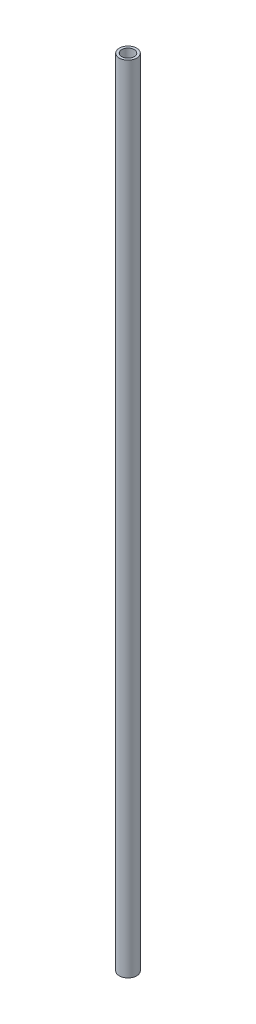
from build123d import *

# Parameters (mm, degrees)
SKETCH1_R           = 13.335
SKETCH1_R_2         = 9.525
BOSS_EXTRUDE1_DEPTH = 1219.2


with BuildPart() as part:
    # Sketch1 → Boss-Extrude1 (new body)
    with BuildSketch(Plane(origin=(0, 0, 0), x_dir=(1, 0, 0), z_dir=(0, 1, 0))):
        Circle(SKETCH1_R)
        Circle(SKETCH1_R_2, mode=Mode.SUBTRACT)
    extrude(amount=BOSS_EXTRUDE1_DEPTH)


solid = part.part
